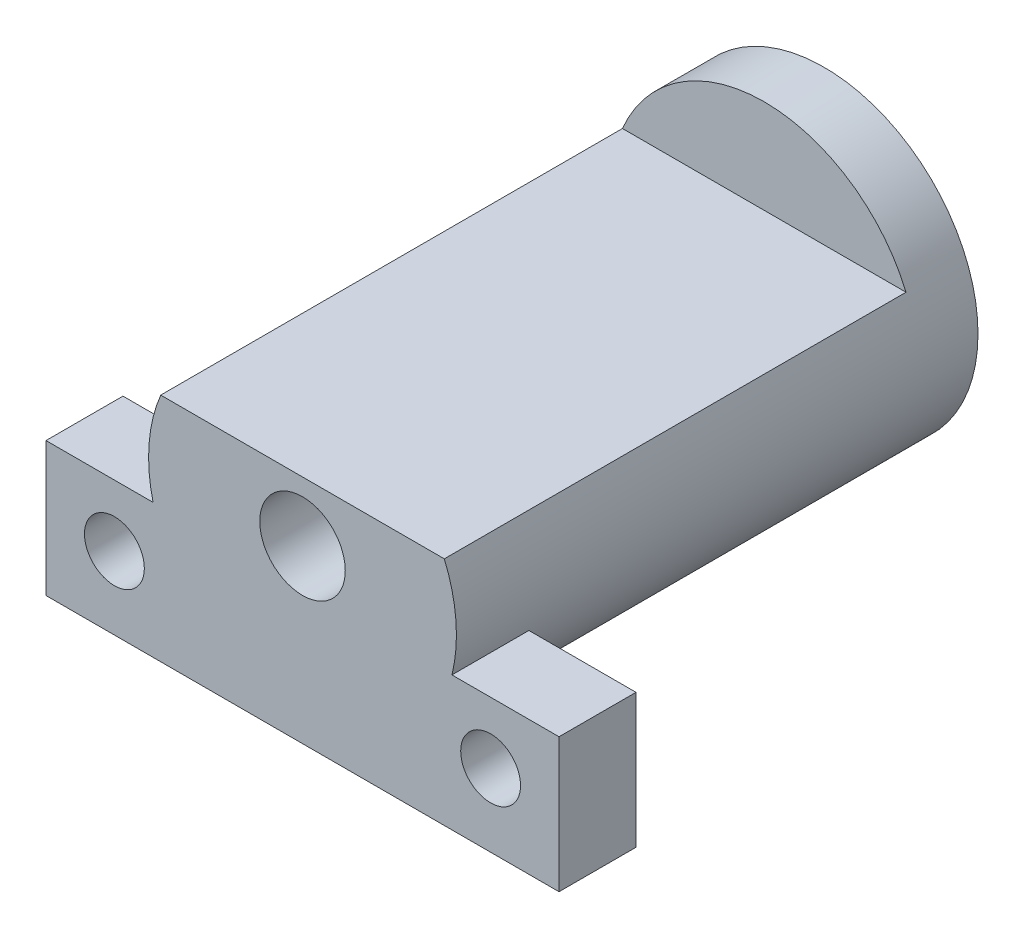
from build123d import *

# Parameters (mm, degrees)
SKETCH1_R           = 18
BOSS_EXTRUDE1_DEPTH = 61
SKETCH2_W           = 39.528935746
SKETCH2_H           = 14.130439677
CUT_EXTRUDE1_DEPTH  = 54
SKETCH3_W           = 60
SKETCH3_H           = 15.7
BOSS_EXTRUDE2_DEPTH = 9
SKETCH4_R           = 3.5
CUT_EXTRUDE2_DEPTH  = 10
LPATTERN1_COUNT     = 2
LPATTERN1_PITCH     = 44
SKETCH6_R           = 5
CUT_EXTRUDE3_DEPTH  = 100


with BuildPart() as part:
    # Sketch1 → Boss-Extrude1 (new body)
    with BuildSketch(Plane.XY):
        Circle(SKETCH1_R)
    extrude(amount=BOSS_EXTRUDE1_DEPTH)

    # Sketch2 → Cut-Extrude1 (cut)
    with BuildSketch(Plane.XY.offset(61)):
        with Locations((2.474682956, 14.065219839)):
            Rectangle(SKETCH2_W, SKETCH2_H)
    extrude(amount=-CUT_EXTRUDE1_DEPTH, mode=Mode.SUBTRACT)

    # Sketch3 → Boss-Extrude2 (add)
    with BuildSketch(Plane.XY.offset(61)):
        with Locations((0, -12.16286005)):
            Rectangle(SKETCH3_W, SKETCH3_H)
    extrude(amount=-BOSS_EXTRUDE2_DEPTH)

    # Sketch4 → Cut-Extrude2 (cut)
    with BuildSketch(Plane(origin=(0, 0, 52), x_dir=(-1, 0, 0), z_dir=(0, 0, -1))):
        with Locations((-22, -11.51286005)):
            Circle(SKETCH4_R)
    cut_extrude2 = extrude(amount=-CUT_EXTRUDE2_DEPTH, mode=Mode.SUBTRACT)

    # LPattern1: Cut-Extrude2 ×2
    with Locations(*[(-i * LPATTERN1_PITCH, 0, 0) for i in range(1, LPATTERN1_COUNT)]):
        add(cut_extrude2, mode=Mode.SUBTRACT)

    # Sketch6 → Cut-Extrude3 (cut)
    with BuildSketch(Plane(origin=(0, 0, 0), x_dir=(-1, 0, 0), z_dir=(0, 0, -1))):
        Circle(SKETCH6_R)
    extrude(amount=-CUT_EXTRUDE3_DEPTH, mode=Mode.SUBTRACT)


solid = part.part
